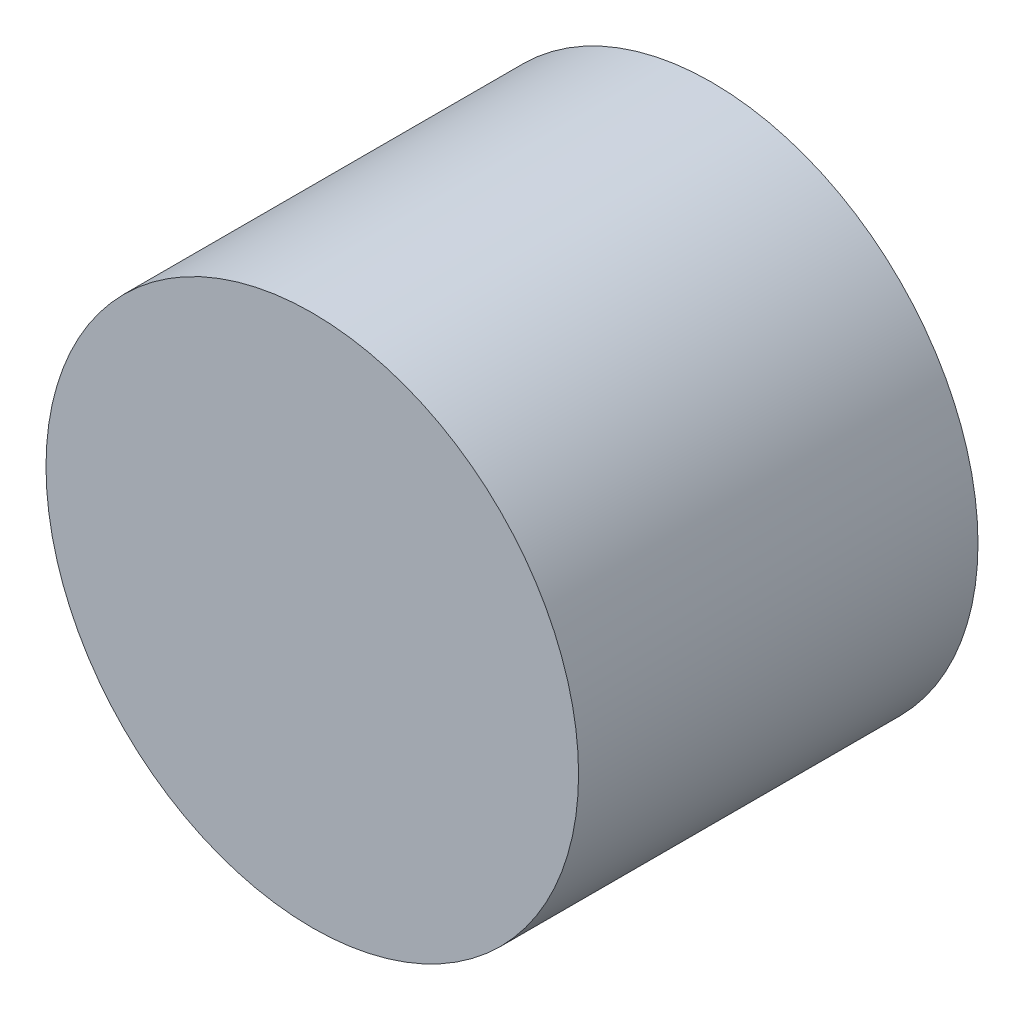
from build123d import *

# Parameters (mm, degrees)
SKETCH1_R           = 6
BOSS_EXTRUDE1_DEPTH = 9


with BuildPart() as part:
    # Sketch1 → Boss-Extrude1 (new body)
    with BuildSketch(Plane.XY):
        Circle(SKETCH1_R)
    extrude(amount=BOSS_EXTRUDE1_DEPTH)


solid = part.part
